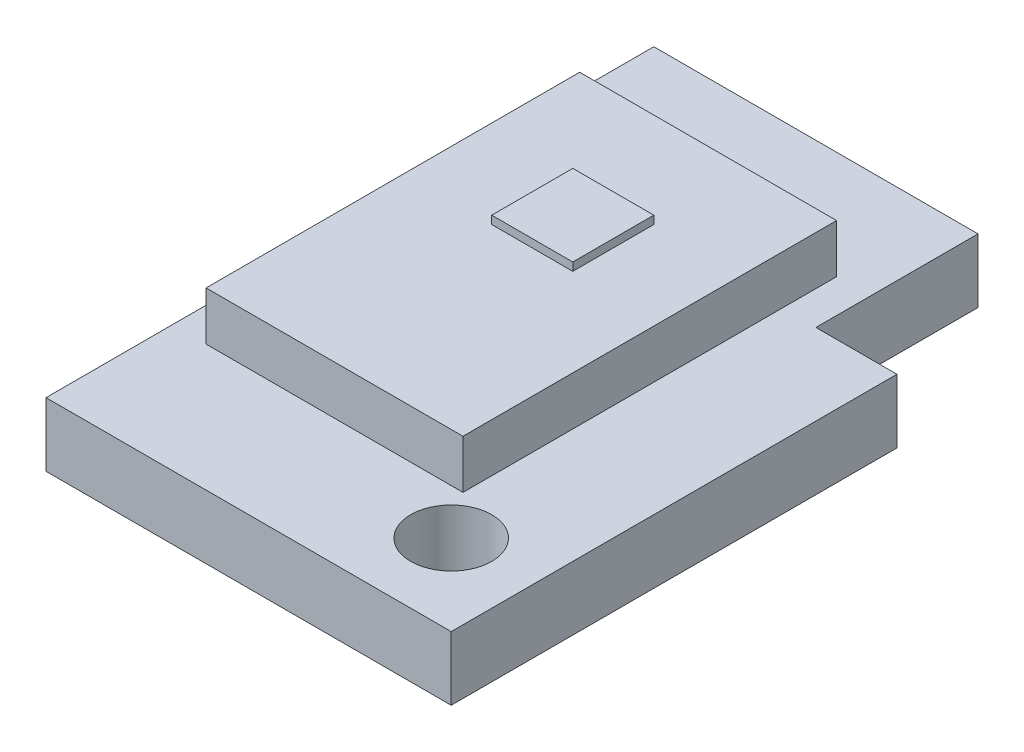
from build123d import *

# Parameters (mm, degrees)
BOSS_EXTRUDE1_DEPTH = 0.7874
SKETCH4_W           = 3.17
SKETCH4_H           = 4.61
BOSS_EXTRUDE3_DEPTH = 0.6
SKETCH2_W           = 1
SKETCH2_H           = 1
BOSS_EXTRUDE2_DEPTH = 0.1
SKETCH5_R           = 0.5
CUT_EXTRUDE1_DEPTH  = 1.7874


with BuildPart() as part:
    # Sketch1 → Boss-Extrude1 (new body)
    with BuildSketch(Plane(origin=(0, 0, 0), x_dir=(1, 0, 0), z_dir=(0, 1, 0))):
        Polygon((2, 3), (2, 1), (3, 1), (3, -4.5), (-2, -4.5), (-2, 3), align=None)
    extrude(amount=BOSS_EXTRUDE1_DEPTH)

    # Sketch4 → Boss-Extrude3 (add)
    with BuildSketch(Plane(origin=(0, 0.7874, 0), x_dir=(1, 0, 0), z_dir=(0, 1, 0))):
        with Locations((0, -0.635)):
            Rectangle(SKETCH4_W, SKETCH4_H)
    extrude(amount=BOSS_EXTRUDE3_DEPTH)

    # Sketch2 → Boss-Extrude2 (add)
    with BuildSketch(Plane(origin=(0, 1.3874, 0), x_dir=(1, 0, 0), z_dir=(0, 1, 0))):
        Rectangle(SKETCH2_W, SKETCH2_H)
    extrude(amount=BOSS_EXTRUDE2_DEPTH)

    # Sketch5 → Cut-Extrude1 (cut, through all)
    with BuildSketch(Plane(origin=(0, 0.7874, 0), x_dir=(1, 0, 0), z_dir=(0, 1, 0))):
        with Locations((2, -3.5)):
            Circle(SKETCH5_R)
    extrude(amount=-CUT_EXTRUDE1_DEPTH, mode=Mode.SUBTRACT)


solid = part.part
